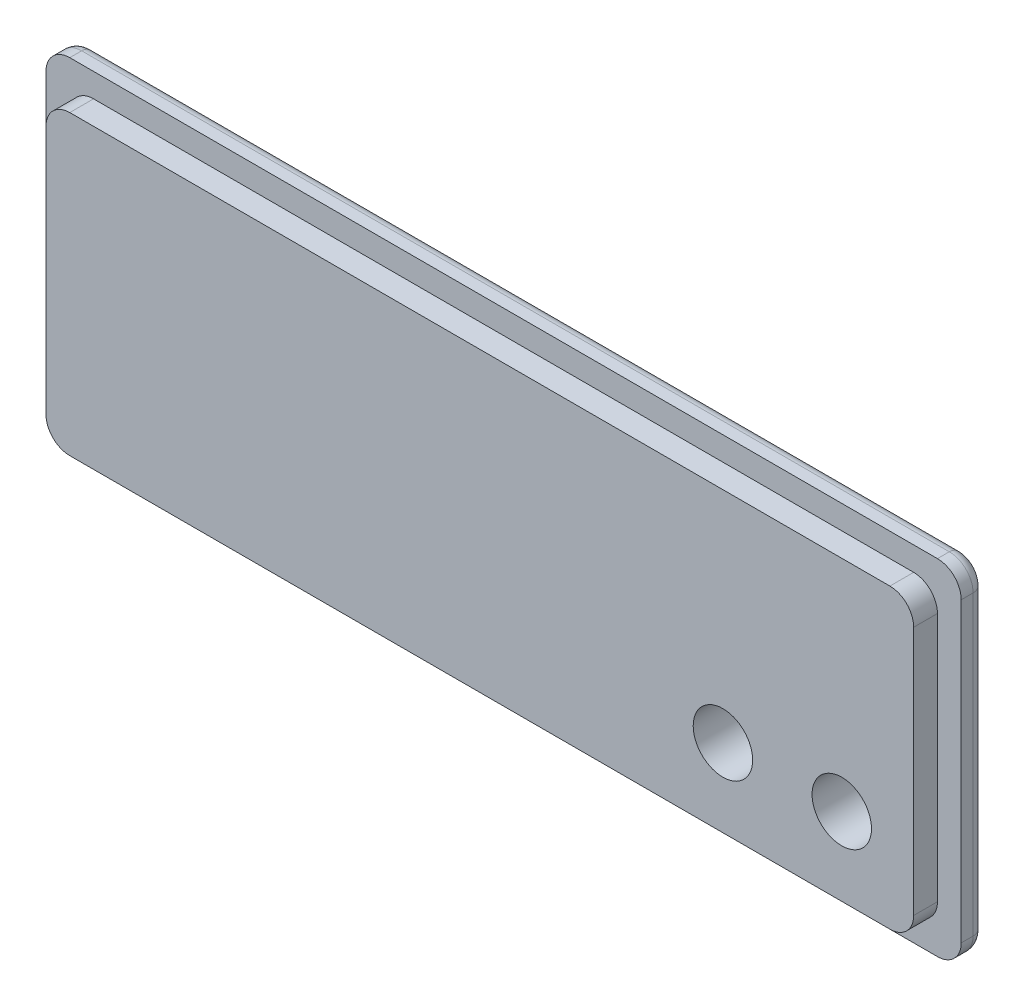
from build123d import *

# Parameters (mm, degrees)
BOSS_EXTRUDE1_DEPTH = 2
BOSS_EXTRUDE2_DEPTH = 2
SKETCH3_R           = 2.5
CUT_EXTRUDE1_DEPTH  = 10
FILLET1_R           = 1


with BuildPart() as part:
    # Sketch1 → Boss-Extrude1 (new body)
    with BuildSketch(Plane.XY):
        with BuildLine():
            Line((36.5, -14.5), (-36.5, -14.5))
            ThreePointArc((-36.5, -14.5), (-37.914213562, -13.914213562), (-38.5, -12.5))
            Line((-38.5, -12.5), (-38.5, 12.5))
            ThreePointArc((-38.5, 12.5), (-37.914213562, 13.914213562), (-36.5, 14.5))
            Line((-36.5, 14.5), (36.5, 14.5))
            ThreePointArc((36.5, 14.5), (37.914213562, 13.914213562), (38.5, 12.5))
            Line((38.5, 12.5), (38.5, -12.5))
            ThreePointArc((38.5, -12.5), (37.914213562, -13.914213562), (36.5, -14.5))
        make_face()
    extrude(amount=BOSS_EXTRUDE1_DEPTH)

    # Sketch2 → Boss-Extrude2 (add)
    with BuildSketch(Plane.XY.offset(2)):
        with BuildLine():
            Line((34.5, -12.5), (-34.5, -12.5))
            ThreePointArc((-34.5, -12.5), (-35.914213562, -11.914213562), (-36.5, -10.5))
            Line((-36.5, -10.5), (-36.5, 10.5))
            ThreePointArc((-36.5, 10.5), (-35.914213562, 11.914213562), (-34.5, 12.5))
            Line((-34.5, 12.5), (34.5, 12.5))
            ThreePointArc((34.5, 12.5), (35.914213562, 11.914213562), (36.5, 10.5))
            Line((36.5, 10.5), (36.5, -10.5))
            ThreePointArc((36.5, -10.5), (35.914213562, -11.914213562), (34.5, -12.5))
        make_face()
    extrude(amount=BOSS_EXTRUDE2_DEPTH)

    # Sketch3 → Cut-Extrude1 (cut)
    with BuildSketch(Plane(origin=(0, 0, 0), x_dir=(-1, 0, 0), z_dir=(0, 0, -1))):
        with Locations((-30.450412323, -5.952241092)):
            Circle(SKETCH3_R)
        with Locations((-20.450412323, -5.952241092)):
            Circle(SKETCH3_R)
    extrude(amount=-CUT_EXTRUDE1_DEPTH, mode=Mode.SUBTRACT)

    # Fillet1
    fillet1_edges = [part.edges().sort_by_distance(p)[0] for p in [
        (38.5, 0, 0),
        (37.914213562, -13.914213562, 0),
        (0, -14.5, 0),
        (-37.914213562, -13.914213562, 0),
        (-38.5, 0, 0),
        (-37.914213562, 13.914213562, 0),
        (0, 14.5, 0),
        (37.914213562, 13.914213562, 0),
    ]]
    fillet(fillet1_edges, radius=FILLET1_R)


solid = part.part
